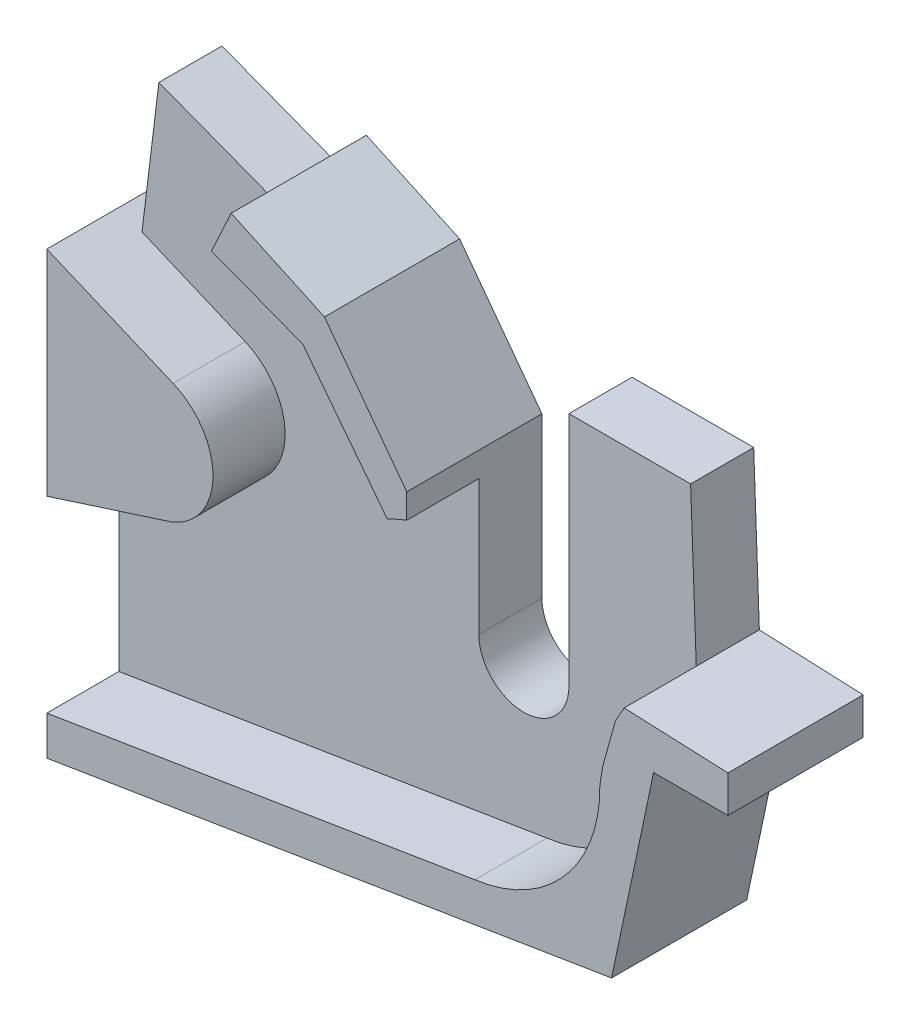
from build123d import *

# Parameters (mm, degrees)
BOSS_EXTRUDE2_DEPTH = 7
BOSS_EXTRUDE3_DEPTH = 15


with BuildPart() as part:
    # Sketch1 → Boss-Extrude2 (new body)
    with BuildSketch(Plane.XY):
        with BuildLine():
            Line((-40.843938812, -25.02529653), (21.822672825, -14.817519442))
            Line((21.822672825, -14.817519442), (26.489801196, 7.266810726))
            Line((26.489801196, 7.266810726), (34.744303123, 7.266810726))
            Line((34.744303123, 7.266810726), (34.744303123, 11.354641566))
            Line((34.744303123, 11.354641566), (23.2245968, 11.838054321))
            Line((23.2245968, 11.838054321), (22.594616957, 29.052034329))
            Line((22.594616957, 29.052034329), (9.094616957, 29.052034329))
            Line((9.094616957, 29.052034329), (9.094616957, 2.846901584))
            ThreePointArc((9.094616957, 2.846901584), (4.094616957, -2.153098416), (-0.905383043, 2.846901584))
            Line((-0.905383043, 2.846901584), (-0.905383043, 20.539136331))
            Line((-0.905383043, 20.539136331), (-10.036820206, 32.783811613))
            Line((-10.036820206, 32.783811613), (-20.38656022, 37.570023616))
            Line((-20.38656022, 37.570023616), (-22.572356812, 32.843440998))
            Line((-22.572356812, 32.843440998), (-36.411901157, 38.132027383))
            Line((-36.411901157, 38.132027383), (-40.843938812, 1.825568171))
            Line((-40.843938812, 1.825568171), (-40.843938812, -25.02529653))
        make_face()
    extrude(amount=BOSS_EXTRUDE2_DEPTH)

    # Sketch1_7 → Boss-Extrude3 (add)
    with BuildSketch(Plane.XY):
        with BuildLine():
            Line((-40.843938812, -20.694070291), (-40.843938812, -25.02529653))
            Line((-40.843938812, -25.02529653), (21.822672825, -14.817519442))
            Line((21.822672825, -14.817519442), (26.489801196, 7.266810726))
            Line((26.489801196, 7.266810726), (34.744303123, 7.266810726))
            Line((34.744303123, 7.266810726), (34.744303123, 11.354641566))
            Line((34.744303123, 11.354641566), (23.2245968, 11.838054321))
            Line((23.2245968, 11.838054321), (22.257186267, 10.122973627))
            Line((22.257186267, 10.122973627), (20.850125794, 5.080010211))
            Line((20.850125794, 5.080010211), (20.523303512, 3.077207951))
            ThreePointArc((20.523303512, 3.077207951), (16.644968484, -7.575511067), (6.665935601, -12.955177206))
            Line((6.665935601, -12.955177206), (-40.843938812, -20.694070291))
        make_face()
        with BuildLine():
            Line((-40.843938812, 23.904400779), (-40.843938812, 0.147997265))
            Line((-40.843938812, 0.147997265), (-26.961449929, 4.612329337))
            ThreePointArc((-26.961449929, 4.612329337), (-22.405428772, 11.264736988), (-26.832821067, 18.003435216))
            Line((-26.832821067, 18.003435216), (-40.843938812, 23.904400779))
        make_face()
        with BuildLine():
            Line((-12.451357463, 28.975844058), (-3.054484565, 16.834095496))
            ThreePointArc((-3.054484565, 16.834095496), (-1.998003486, 17.361409284), (-0.905383043, 17.809061684))
            Line((-0.905383043, 17.809061684), (-0.905383043, 20.539136331))
            Line((-0.905383043, 20.539136331), (-10.036820206, 32.783811613))
            Line((-10.036820206, 32.783811613), (-20.38656022, 37.570023616))
            Line((-20.38656022, 37.570023616), (-22.572356812, 32.843440998))
            Line((-22.572356812, 32.843440998), (-12.451357463, 28.975844058))
        make_face()
    extrude(amount=BOSS_EXTRUDE3_DEPTH)


solid = part.part
